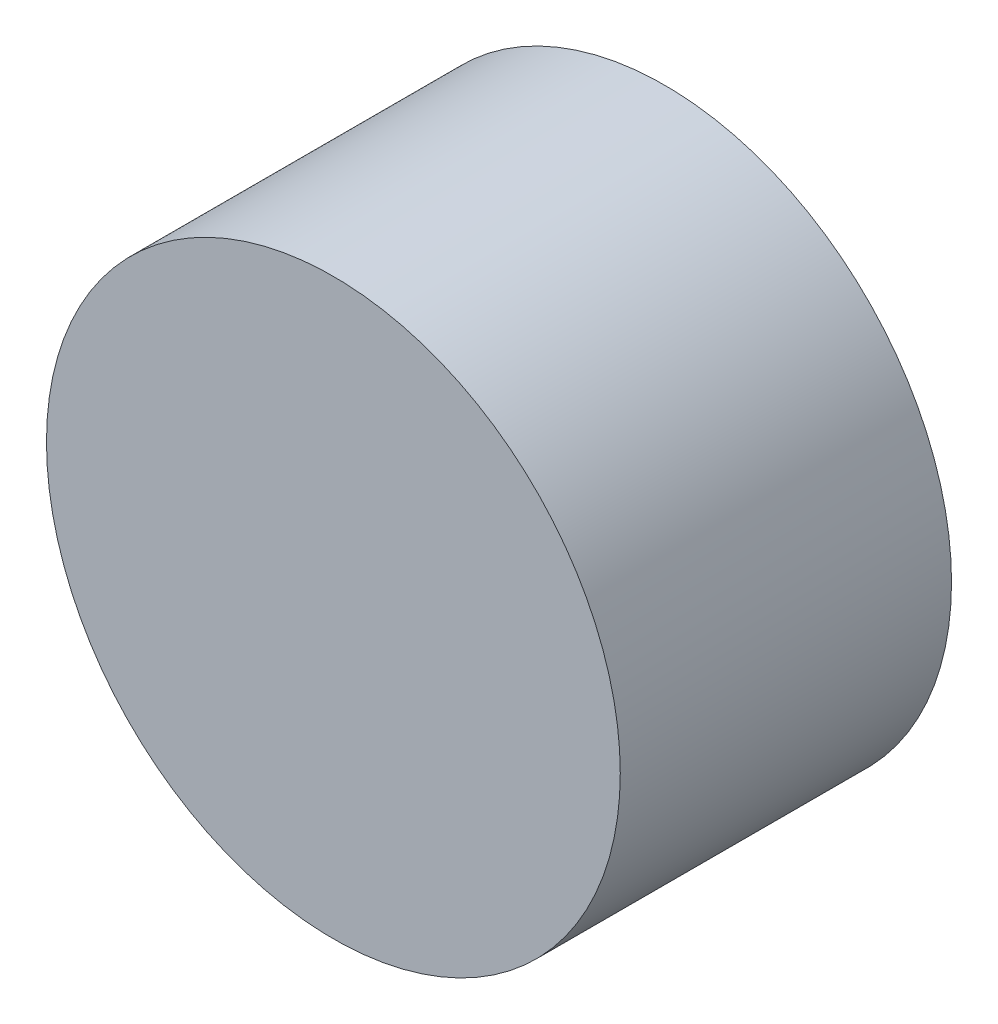
from build123d import *

# Parameters (mm, degrees)
BOSS_EXTRUDE2_DEPTH = 6.35


with BuildPart() as part:
    # Sketch1 → Boss-Extrude2 (new body)
    with BuildSketch(Plane.XY):
        with BuildLine():
            ThreePointArc((-2.5, 4.898979486), (0, -5.5), (2.5, 4.898979486))
            ThreePointArc((2.5, 4.898979486), (0, 5.5), (-2.5, 4.898979486))
        make_face()
    extrude(amount=BOSS_EXTRUDE2_DEPTH)


solid = part.part
